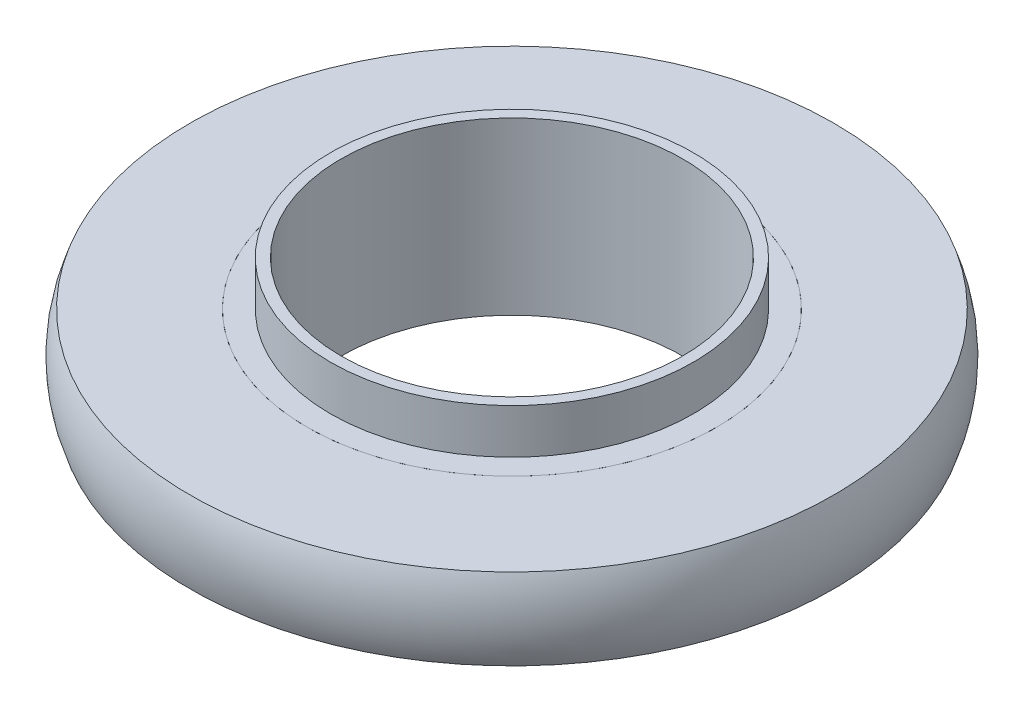
from build123d import *


with BuildPart() as part:
    # Sketch1 → Revolve1 (revolve)
    with BuildSketch(Plane.XY):
        with BuildLine():
            Line((8, 4), (8, -4))
            Line((8, -4), (8.5, -4))
            Line((8.5, -4), (8.5, -1.905))
            Line((8.5, -1.905), (9.589196223, -1.905))
            ThreePointArc((9.589196223, -1.905), (9.235, 0), (9.589196223, 1.905))
            Line((9.589196223, 1.905), (8.5, 1.905))
            Line((8.5, 1.905), (8.5, 4))
            Line((8.5, 4), (8, 4))
        make_face()
    revolve(axis=Axis((0, 4, 0), (0, -1, 0)))


with BuildPart() as body_2:
    # Sketch2 → Revolve2 (revolve)
    with BuildSketch(Plane.XY):
        with BuildLine():
            Line((9.589196223, 1.905), (15.080803777, 1.905))
            ThreePointArc((15.080803777, 1.905), (15.435, 0), (15.080803777, -1.905))
            Line((15.080803777, -1.905), (9.589196223, -1.905))
            ThreePointArc((9.589196223, -1.905), (9.235, 0), (9.589196223, 1.905))
        make_face()
    revolve(axis=Axis((0, -4, 0), (0, 1, 0)))


solid = Compound([part.part, body_2.part])
